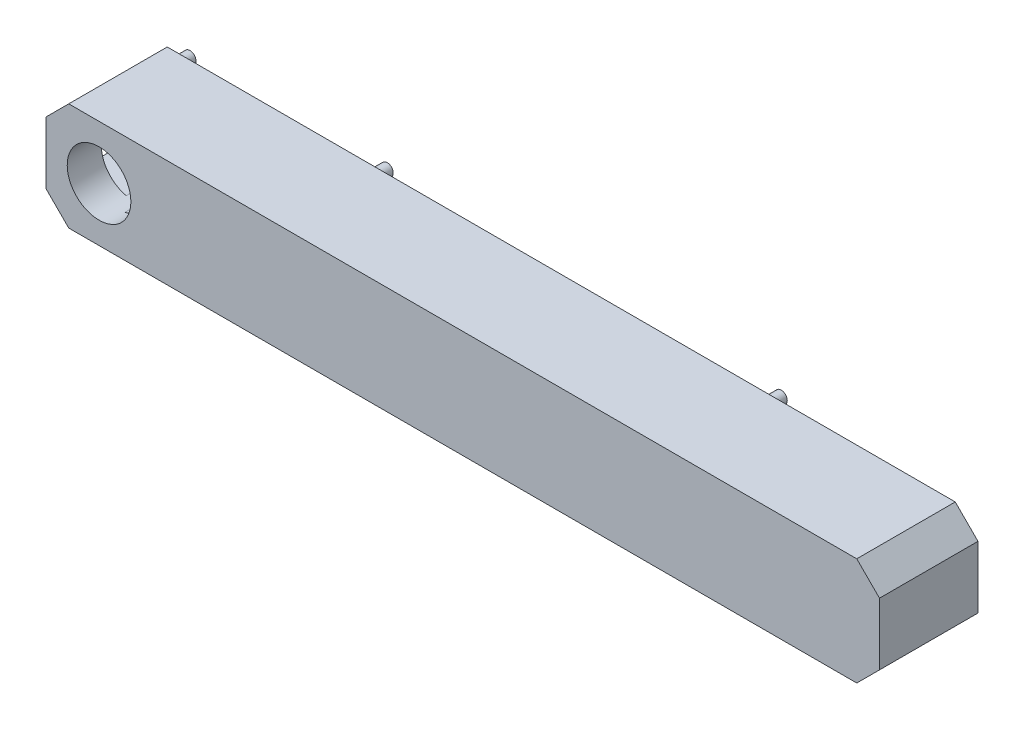
from build123d import *
from build123d.topology import SkipClean

# Parameters (mm, degrees)
SKETCH_4_R          = 4.2
EXTRUDE_5_DEPTH     = 2.5
EXTRUDE_START       = -10.5
EXTRUDE_6_DEPTH     = 10.5
SKETCH_6_R          = 1
CUT_EXTRUDE_2_DEPTH = 2
SKETCH_7_R          = 0.8
EXTRUDE_7_DEPTH     = 2
SKETCH_8_R          = 0.8
EXTRUDE_8_DEPTH     = 2
SKETCH_9_R          = 1
CUT_EXTRUDE_3_DEPTH = 2
CUT_EXTRUDE_6_DEPTH = 5
EXTRUDE_9_DEPTH     = 11
EXTRUDE_10_DEPTH    = 11
EXTRUDE_START_2     = 2
EXTRUDE_11_DEPTH    = 2
SKETCH_18_R         = 1
CUT_EXTRUDE_7_DEPTH = 2
SKETCH_19_R         = 0.8
EXTRUDE_13_DEPTH    = 2
SKETCH_20_W         = 8.5
SKETCH_20_H         = 8.2
CUT_EXTRUDE_8_DEPTH = 10


with BuildPart() as part:
    # 草图4 → 凸台-拉伸5 (new body)
    with BuildSketch(Plane.XY):
        Polygon((52.944203822, -8.2), (52.944203822, 0), (49.944203822, 3), (-54.055796178, 3), (-57.055796178, 0), (-57.055796178, -8.2), (-54.055796178, -11.2), (49.944203822, -11.2), align=None)
        with Locations((-50.055796178, -4.1)):
            Circle(SKETCH_4_R, mode=Mode.SUBTRACT)
    extrude(amount=EXTRUDE_5_DEPTH)

    # 草图4<6> → 凸台-拉伸6 (add)
    with BuildSketch(Plane.XY.offset(EXTRUDE_START)):
        Polygon((52.944203822, -8.2), (52.944203822, 0), (49.944203822, 3), (-54.055796178, 3), (-57.055796178, 0), (-57.055796178, -8.2), (-54.055796178, -11.2), (49.944203822, -11.2), align=None)
        with BuildLine():
            ThreePointArc((-49.14475282, -8.2), (-54.255796178, -4.1), (-49.14475282, 0))
            Line((-49.14475282, 0), (49.944203822, 0))
            Line((49.944203822, 0), (49.944203822, -8.2))
            Line((49.944203822, -8.2), (-49.14475282, -8.2))
        make_face(mode=Mode.SUBTRACT)
    extrude(amount=EXTRUDE_6_DEPTH)

    # 草图6 → 切除-拉伸2 (cut)
    with BuildSketch(Plane(origin=(0, 0, -10.5), x_dir=(-1, 0, 0), z_dir=(0, 0, -1))):
        with Locations((0.055796178, 1.5)):
            Circle(SKETCH_6_R)
    extrude(amount=-CUT_EXTRUDE_2_DEPTH, mode=Mode.SUBTRACT)

    # 草图7 → 凸台-拉伸7 (add)
    with BuildSketch(Plane(origin=(0, 0, -10.5), x_dir=(-1, 0, 0), z_dir=(0, 0, -1))):
        with Locations((-0.399725501, -9.7)):
            Circle(SKETCH_7_R)
    extrude(amount=EXTRUDE_7_DEPTH)

    # 草图8 → 凸台-拉伸8 (add)
    with BuildSketch(Plane(origin=(0, 0, -10.5), x_dir=(-1, 0, 0), z_dir=(0, 0, -1))):
        with Locations((-24.972101911, 1.5)):
            Circle(SKETCH_8_R)
        with Locations((27.027898089, 1.5)):
            Circle(SKETCH_8_R)
    extrude(amount=EXTRUDE_8_DEPTH)

    # 草图9 → 切除-拉伸3 (cut)
    with BuildSketch(Plane(origin=(0, 0, -10.5), x_dir=(-1, 0, 0), z_dir=(0, 0, -1))):
        with Locations((-25.171964661, -9.7)):
            Circle(SKETCH_9_R)
        with Locations((26.828035339, -9.7)):
            Circle(SKETCH_9_R)
    extrude(amount=-CUT_EXTRUDE_3_DEPTH, mode=Mode.SUBTRACT)

    # 草图11 → 切除-拉伸6 (cut)
    with BuildSketch(Plane.ZY.offset(57.055796178)):
        Polygon((0, -8.2), (0, 0), (-10.5, 0), (-10.5, -1.6), (-10.5, -6.6), (-10.5, -8.2), align=None)
    extrude(amount=-CUT_EXTRUDE_6_DEPTH, mode=Mode.SUBTRACT)

    # 草图12 → 凸台-拉伸9 (add)
    with BuildSketch(Plane(origin=(0, 0, -10.5), x_dir=(-1, 0, 0), z_dir=(0, 0, -1))):
        Polygon((52.055796178, -0.406762937), (57.055796178, 0), (52.055796178, 0), align=None)
    extrude(amount=-EXTRUDE_9_DEPTH)

    # 草图13 → 凸台-拉伸10 (add)
    with BuildSketch(Plane(origin=(0, 0, -10.5), x_dir=(-1, 0, 0), z_dir=(0, 0, -1))):
        Polygon((52.055796178, -7.793237063), (52.055796178, -8.2), (57.055796178, -8.2), align=None)
    extrude(amount=-EXTRUDE_10_DEPTH)

    # 草图15 → 凸台-拉伸11 (add)
    with SkipClean():  # the faces are left unmerged after this step: merging them gives an invalid solid
        with BuildSketch(Plane(origin=(0, 0, 0), x_dir=(-1, 0, 0), z_dir=(0, 0, -1)).offset(EXTRUDE_START_2)):
            with BuildLine():
                Line((52.055796178, -0.406762937), (57.055796178, 0))
                Line((57.055796178, 0), (57.055796178, -8.2))
                Line((57.055796178, -8.2), (52.055796178, -7.793237063))
                ThreePointArc((52.055796178, -7.793237063), (54.255796178, -4.1), (52.055796178, -0.406762937))
            make_face()
        extrude(amount=-EXTRUDE_11_DEPTH)

    # 草图18 → 切除-拉伸7 (cut)
    with SkipClean():  # the faces are left unmerged after this step: merging them gives an invalid solid
        with BuildSketch(Plane(origin=(0, 0, -10.5), x_dir=(-1, 0, 0), z_dir=(0, 0, -1))):
            with Locations((53.055796178, -9.496618531)):
                Circle(SKETCH_18_R)
        extrude(amount=-CUT_EXTRUDE_7_DEPTH, mode=Mode.SUBTRACT)

    # 草图19 → 凸台-拉伸13 (add)
    with SkipClean():  # the faces are left unmerged after this step: merging them gives an invalid solid
        with BuildSketch(Plane(origin=(0, 0, -10.5), x_dir=(-1, 0, 0), z_dir=(0, 0, -1))):
            with Locations((53.055796178, 1.296618531)):
                Circle(SKETCH_19_R)
        extrude(amount=EXTRUDE_13_DEPTH)

    # 草图20 → 切除-拉伸8 (cut)
    with SkipClean():  # the faces are left unmerged after this step: merging them gives an invalid solid
        with BuildSketch(Plane.ZY.offset(57.055796178)):
            with Locations((-6.25, -4.1)):
                Rectangle(SKETCH_20_W, SKETCH_20_H)
        extrude(amount=-CUT_EXTRUDE_8_DEPTH, mode=Mode.SUBTRACT)


solid = part.part
